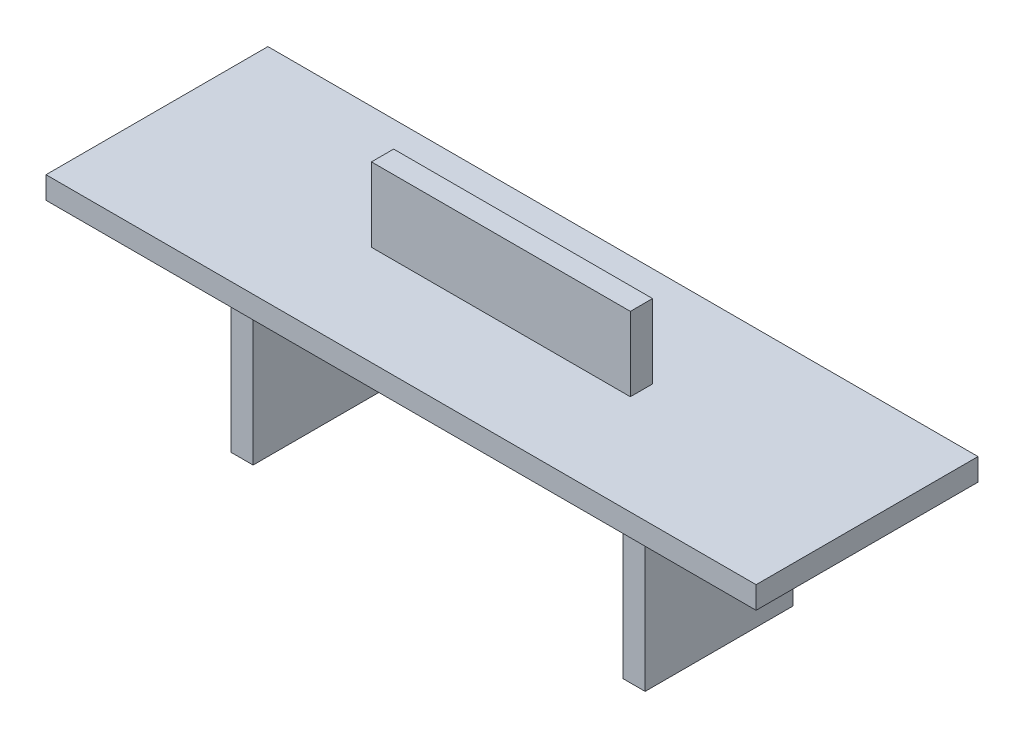
from build123d import *

# Parameters (mm, degrees)
BOSS_EXTRUDE1_DEPTH = 30
SKETCH2_W           = 5
SKETCH2_H           = 22
CUT_EXTRUDE1_DEPTH  = 77
SKETCH3_W           = 35
SKETCH3_H           = 3
BOSS_EXTRUDE2_DEPTH = 10


with BuildPart() as part:
    # Sketch1 → Boss-Extrude1 (new body)
    with BuildSketch(Plane.XY):
        Polygon((-48, 3), (48, 3), (48, 0), (28, 0), (28, -22), (25, -22), (25, 0), (-25, 0), (-25, -22), (-28, -22), (-28, 0), (-48, 0), align=None)
    extrude(amount=BOSS_EXTRUDE1_DEPTH)

    # Sketch2 → Cut-Extrude1 (cut, through all)
    with BuildSketch(Plane.ZY.offset(28)):
        with Locations((2.5, -11)):
            Rectangle(SKETCH2_W, SKETCH2_H)
        with Locations((27.5, -11)):
            Rectangle(SKETCH2_W, SKETCH2_H)
    extrude(amount=-CUT_EXTRUDE1_DEPTH, mode=Mode.SUBTRACT)

    # Sketch3 → Boss-Extrude2 (add)
    with BuildSketch(Plane(origin=(0, 3, 0), x_dir=(1, 0, 0), z_dir=(0, 1, 0))):
        with Locations((0, -15)):
            Rectangle(SKETCH3_W, SKETCH3_H)
    extrude(amount=BOSS_EXTRUDE2_DEPTH)


solid = part.part
